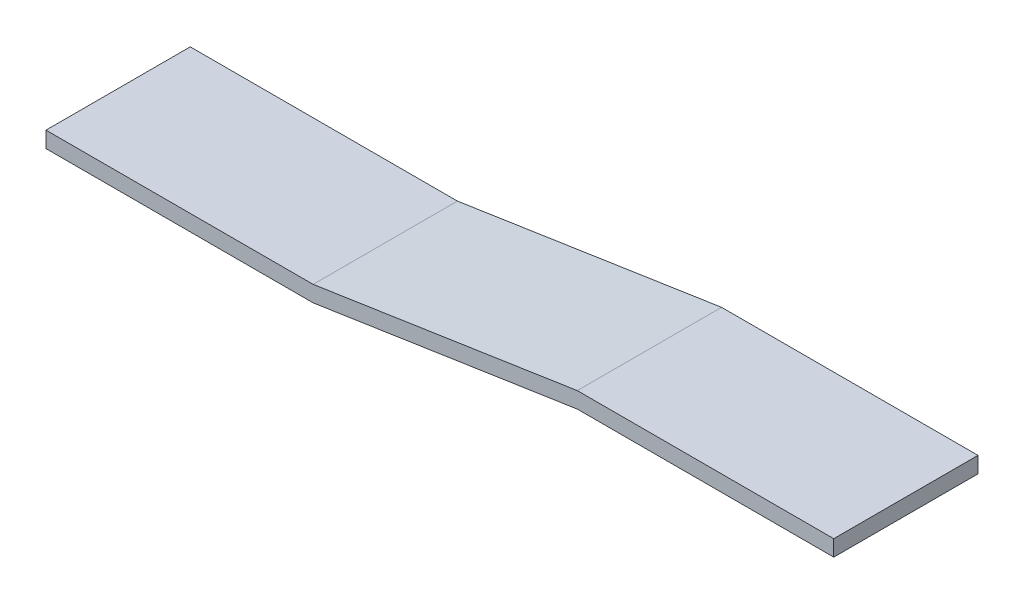
from build123d import *

# Parameters (mm, degrees)
BOSS_EXTRU_1_DEPTH = 27


with BuildPart() as part:
    # Esquisse1 → Boss.-Extru.1 (new body)
    with BuildSketch(Plane.XY):
        Polygon((-24, -1.5), (-73.434299833, -9), (-123.434299833, -9), (-123.434299833, -6), (-73.434299833, -6), (-24, 1.5), (24, 1.5), (24, -1.5), align=None)
    extrude(amount=BOSS_EXTRU_1_DEPTH)


solid = part.part
